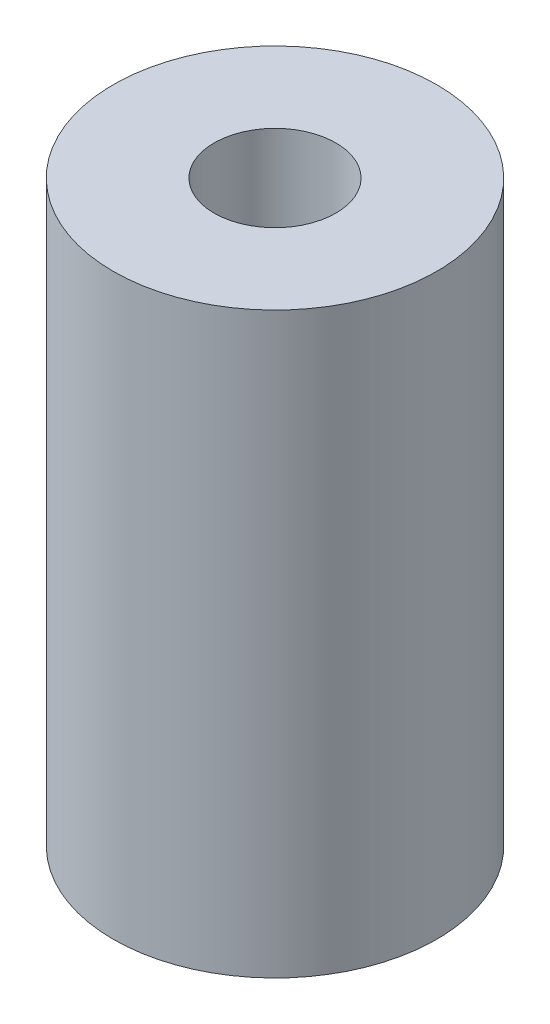
from build123d import *

# Parameters (mm, degrees)
SKETCH2_R      = 42.6085
SKETCH2_R_2    = 16.0401
EXTRUDE1_DEPTH = 152.4


with BuildPart() as part:
    # Sketch2 → Extrude1 (new body)
    with BuildSketch(Plane(origin=(0, 0, 0), x_dir=(1, 0, 0), z_dir=(0, 1, 0))):
        Circle(SKETCH2_R)
        Circle(SKETCH2_R_2, mode=Mode.SUBTRACT)
    extrude(amount=EXTRUDE1_DEPTH)


solid = part.part
